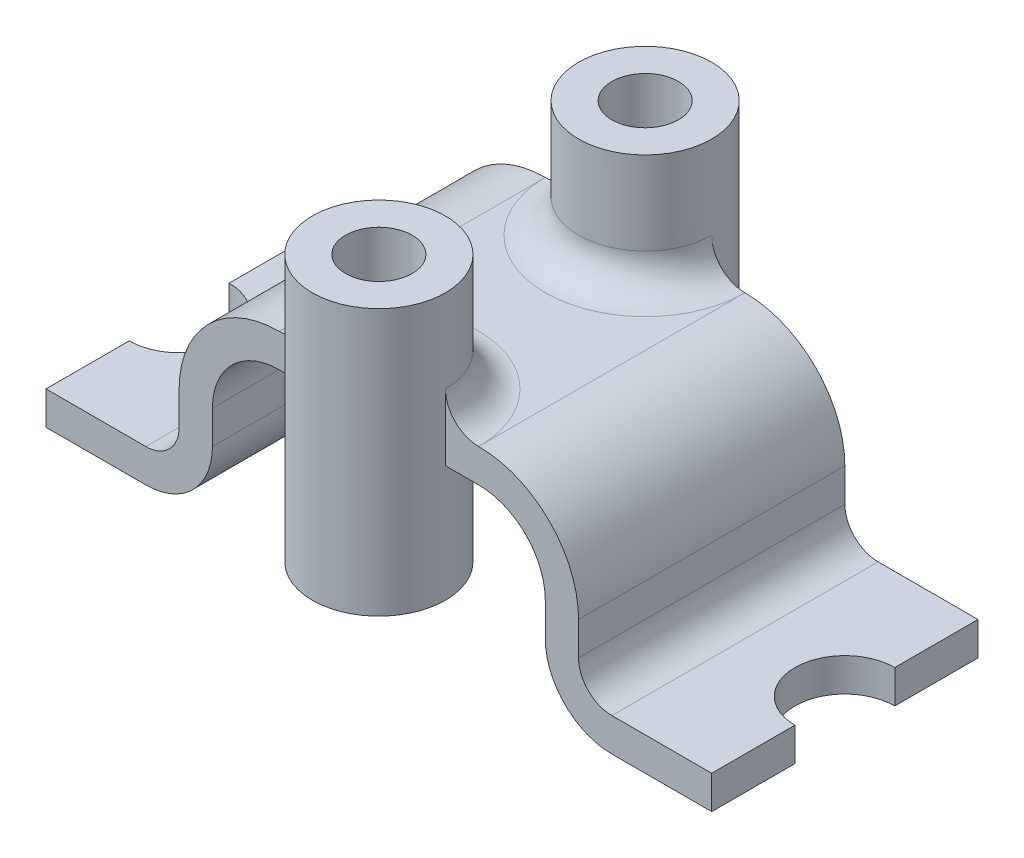
from build123d import *

# Parameters (mm, degrees)
SKETCH1_W           = 60
SKETCH1_H           = 40
BOSS_EXTRUDE3_DEPTH = 2.5
SKETCH3_R           = 10
SKETCH3_R_2         = 5
BOSS_EXTRUDE4_DEPTH = 20
FILLET7_R           = 5
SKETCH4_W           = 5
SKETCH4_H           = 40
BOSS_EXTRUDE6_DEPTH = 25
SKETCH5_W           = 40
SKETCH5_H           = 5
BOSS_EXTRUDE7_DEPTH = 20
FILLET8_R           = 5
FILLET9_R           = 10
FILLET10_R          = 15
SKETCH6_R           = 7.5
CUT_EXTRUDE1_DEPTH  = 20


with BuildPart() as part:
    # Sketch1 → Boss-Extrude3 (new, symmetric)
    with BuildSketch(Plane(origin=(0, 0, 0), x_dir=(1, 0, 0), z_dir=(0, 1, 0))):
        Rectangle(SKETCH1_W, SKETCH1_H)
    extrude(amount=BOSS_EXTRUDE3_DEPTH, both=True)

    # Sketch3 → Boss-Extrude4 (add, symmetric)
    with BuildSketch(Plane(origin=(0, 0, 0), x_dir=(1, 0, 0), z_dir=(0, 1, 0))):
        with Locations(Location((0, -20, 0), (0, 0, 270))):
            Circle(SKETCH3_R)
        with Locations(Location((0, -20, 0), (0, 0, 270))):
            Circle(SKETCH3_R_2, mode=Mode.SUBTRACT)
        with Locations(Location((0, 20, 0), (0, 0, 90))):
            Circle(SKETCH3_R)
        with Locations(Location((0, 20, 0), (0, 0, 90))):
            Circle(SKETCH3_R_2, mode=Mode.SUBTRACT)
    extrude(amount=BOSS_EXTRUDE4_DEPTH, both=True)

    # Fillet7
    fillet7_edges = [part.edges().sort_by_distance(p)[0] for p in [
        (0, 2.5, 10),
        (0, 2.5, -10),
    ]]
    fillet(fillet7_edges, radius=FILLET7_R)

    # Sketch4 → Boss-Extrude6 (add)
    with BuildSketch(Plane.XZ.offset(2.5)):
        with Locations((27.5, 0)):
            Rectangle(SKETCH4_W, SKETCH4_H)
        with Locations((-27.5, 0)):
            Rectangle(SKETCH4_W, SKETCH4_H)
    extrude(amount=BOSS_EXTRUDE6_DEPTH)

    # Sketch5 → Boss-Extrude7 (add)
    with BuildSketch(Plane(origin=(30, 0, 0), x_dir=(0, 0, -1), z_dir=(1, 0, 0))):
        with Locations((0, -25)):
            Rectangle(SKETCH5_W, SKETCH5_H)
    boss_extrude7 = extrude(amount=BOSS_EXTRUDE7_DEPTH)

    # Mirror1: Boss-Extrude7 across plane
    add(boss_extrude7.mirror(Plane(origin=(0, 0, 0), x_dir=(0, 0, 1), z_dir=(1, 0, 0))))

    # Fillet8
    fillet8_edges = [part.edges().sort_by_distance(p)[0] for p in [
        (30, -22.5, 0),
        (-30, -22.5, 0),
    ]]
    fillet(fillet8_edges, radius=FILLET8_R)

    # Fillet9
    fillet9_edges = [part.edges().sort_by_distance(p)[0] for p in [
        (25, -2.5, 0),
        (25, -27.5, 0),
        (-25, -2.5, 0),
        (-25, -27.5, 0),
    ]]
    fillet(fillet9_edges, radius=FILLET9_R)

    # Fillet10
    fillet10_edges = [part.edges().sort_by_distance(p)[0] for p in [
        (30, 2.5, 0),
        (-30, 2.5, 0),
    ]]
    fillet(fillet10_edges, radius=FILLET10_R)

    # Sketch6 → Cut-Extrude1 (cut)
    with BuildSketch(Plane(origin=(0, -22.5, 0), x_dir=(1, 0, 0), z_dir=(0, 1, 0))):
        with Locations((50, 0)):
            Circle(SKETCH6_R)
        with Locations((-50, 0)):
            Circle(SKETCH6_R)
    extrude(amount=-CUT_EXTRUDE1_DEPTH, mode=Mode.SUBTRACT)


solid = part.part
